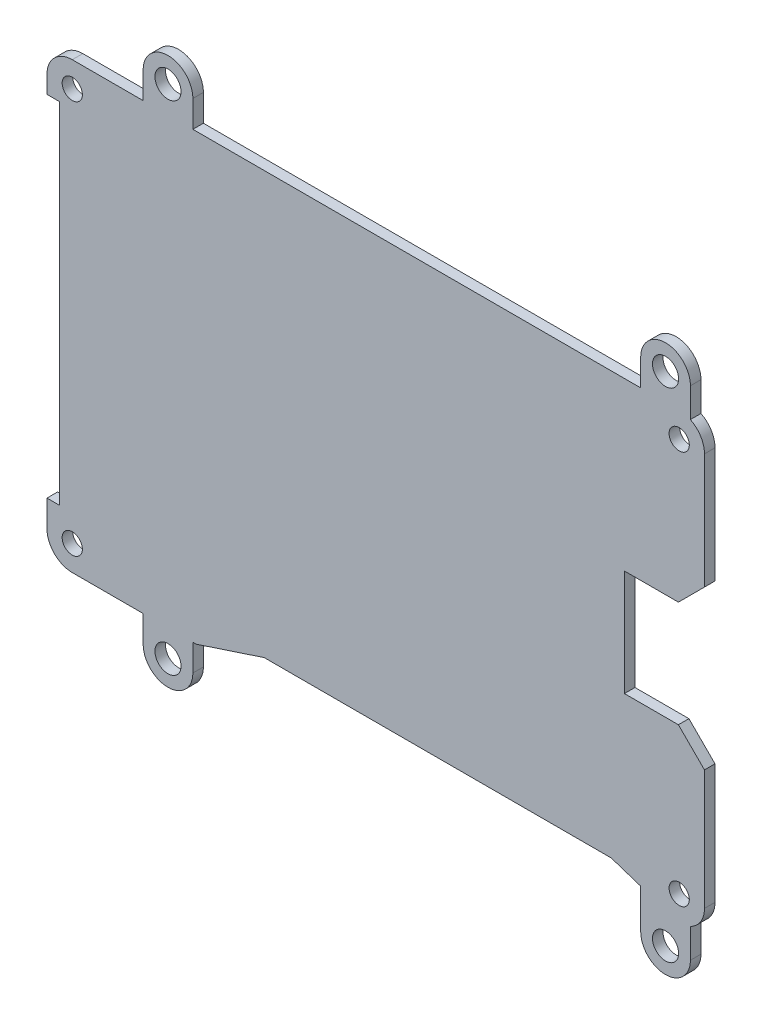
from build123d import *

# Parameters (mm, degrees)
SKETCH1_R           = 1.524
BOSS_EXTRUDE1_DEPTH = 1.5875
SKETCH8_R           = 3.7465
SKETCH8_R_2         = 1.9685
BOSS_EXTRUDE6_DEPTH = 1.5875


with BuildPart() as part:
    # Sketch1 → Boss-Extrude1 (new body)
    with BuildSketch(Plane.XY):
        with BuildLine():
            Line((-301.9473, 133.57775), (-305.87795, 129.6471))
            Line((-305.87795, 129.6471), (-314.0123, 129.6471))
            Line((-314.0123, 129.6471), (-314.0123, 113.6451))
            Line((-314.0123, 113.6451), (-305.87795, 113.6451))
            Line((-305.87795, 113.6451), (-301.9473, 109.71445))
            Line((-301.9473, 109.71445), (-301.9473, 91.6317))
            ThreePointArc((-301.9473, 91.6317), (-303.063223164, 88.937623164), (-305.7573, 87.8217))
            Line((-305.7573, 87.8217), (-315.9973, 91.1883))
            Line((-315.9973, 91.1883), (-368.3165, 91.1883))
            Line((-368.3165, 91.1883), (-378.5565, 87.8217))
            Line((-378.5565, 87.8217), (-397.2472, 87.8217))
            ThreePointArc((-397.2472, 87.8217), (-399.951018769, 88.947400452), (-401.0571, 91.659304166))
            Line((-401.0571, 91.659304166), (-401.0571, 95.6449))
            Line((-401.0571, 95.6449), (-399.1521, 95.6449))
            Line((-399.1521, 95.6449), (-399.1521, 148.341))
            Line((-399.1521, 148.341), (-401.0571, 148.341))
            Line((-401.0571, 148.341), (-401.0571, 150.956597849))
            ThreePointArc((-401.0571, 150.956597849), (-399.946077222, 153.659592612), (-397.247125, 154.7804))
            Line((-397.247125, 154.7804), (-305.7573, 154.7804))
            ThreePointArc((-305.7573, 154.7804), (-303.063223164, 153.664476836), (-301.9473, 150.9704))
            Line((-301.9473, 150.9704), (-301.9473, 133.57775))
        make_face()
        with Locations((-305.7573, 150.9704)):
            Circle(SKETCH1_R, mode=Mode.SUBTRACT)
        with Locations((-397.247125, 150.9704)):
            Circle(SKETCH1_R, mode=Mode.SUBTRACT)
        with Locations((-397.2472, 91.6317)):
            Circle(SKETCH1_R, mode=Mode.SUBTRACT)
        with Locations((-305.7573, 91.6317)):
            Circle(SKETCH1_R, mode=Mode.SUBTRACT)
    extrude(amount=BOSS_EXTRUDE1_DEPTH)

    # Sketch8 → Boss-Extrude6 (add)
    with BuildSketch(Plane.XY.offset(1.5875)):
        with BuildLine():
            ThreePointArc((-379.068128555, 158.80105), (-382.814628555, 155.05455), (-386.561128555, 158.80105))
            Line((-386.561128555, 158.80105), (-386.561128555, 154.7804))
            Line((-386.561128555, 154.7804), (-379.068128555, 154.7804))
            Line((-379.068128555, 154.7804), (-379.068128555, 158.80105))
        make_face()
        with Locations((-382.814628555, 158.80105)):
            Circle(SKETCH8_R)
        with Locations((-382.814628555, 158.80105)):
            Circle(SKETCH8_R_2, mode=Mode.SUBTRACT)
        with BuildLine():
            Line((-311.561128555, 158.80105), (-311.561128555, 154.7804))
            Line((-311.561128555, 154.7804), (-305.7573, 154.7804))
            ThreePointArc((-305.7573, 154.7804), (-304.889939249, 154.680357591), (-304.068128555, 154.385484162))
            Line((-304.068128555, 154.385484162), (-304.068128555, 158.80105))
            ThreePointArc((-304.068128555, 158.80105), (-307.814628555, 155.05455), (-311.561128555, 158.80105))
        make_face()
        with Locations((-307.814628555, 158.80105)):
            Circle(SKETCH8_R)
        with Locations((-307.814628555, 158.80105)):
            Circle(SKETCH8_R_2, mode=Mode.SUBTRACT)
        with BuildLine():
            Line((-311.561128555, 89.729821994), (-311.561128555, 83.80105))
            ThreePointArc((-311.561128555, 83.80105), (-307.814628555, 87.54755), (-304.068128555, 83.80105))
            Line((-304.068128555, 83.80105), (-304.068128555, 88.216615838))
            ThreePointArc((-304.068128555, 88.216615838), (-304.889939249, 87.921742409), (-305.7573, 87.8217))
            Line((-305.7573, 87.8217), (-311.561128555, 89.729821994))
        make_face()
        with Locations((-307.814628555, 83.80105)):
            Circle(SKETCH8_R)
        with Locations((-307.814628555, 83.80105)):
            Circle(SKETCH8_R_2, mode=Mode.SUBTRACT)
        with BuildLine():
            ThreePointArc((-386.561128555, 83.80105), (-382.814628555, 87.54755), (-379.068128555, 83.80105))
            Line((-379.068128555, 83.80105), (-379.068128555, 87.8217))
            Line((-379.068128555, 87.8217), (-386.561128555, 87.8217))
            Line((-386.561128555, 87.8217), (-386.561128555, 83.80105))
        make_face()
        with Locations((-382.814628555, 83.80105)):
            Circle(SKETCH8_R)
        with Locations((-382.814628555, 83.80105)):
            Circle(SKETCH8_R_2, mode=Mode.SUBTRACT)
    extrude(amount=-BOSS_EXTRUDE6_DEPTH)


solid = part.part
